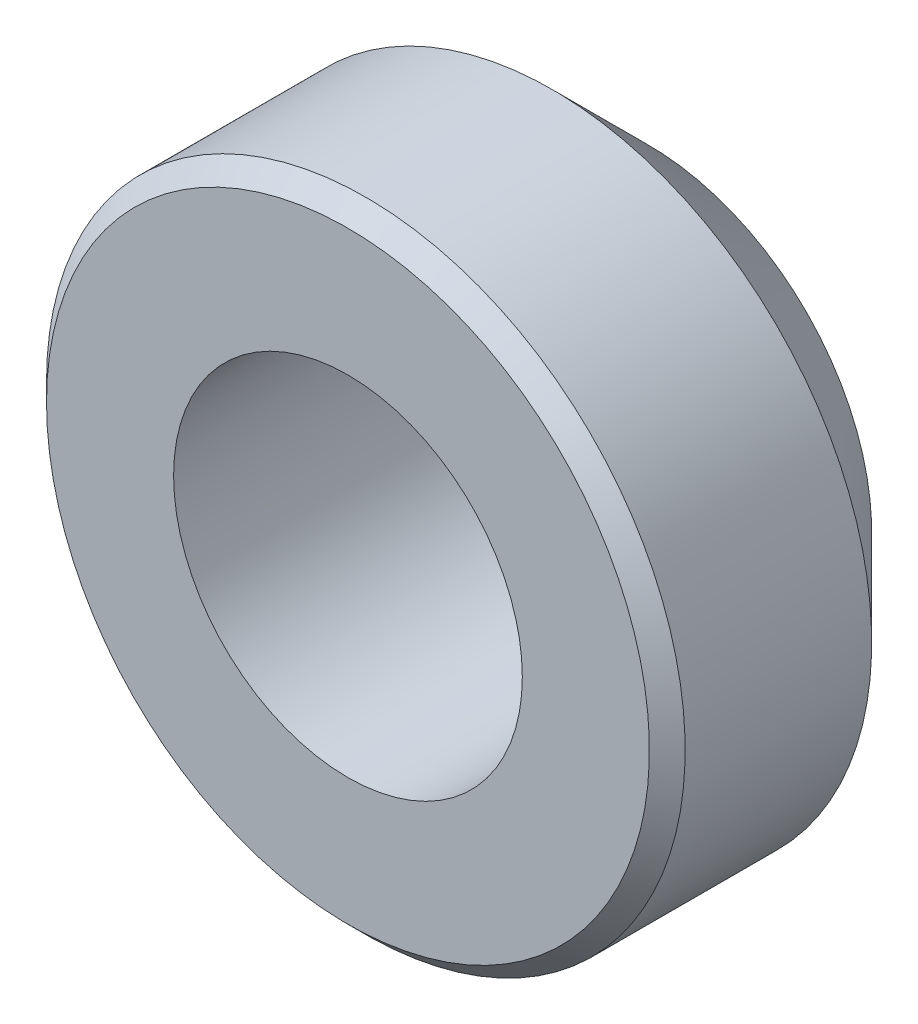
from build123d import *

# Parameters (mm, degrees)
SKETCH2_R          = 1.73355
CUT_EXTRUDE1_DEPTH = 3.9845
CHAMFER1_SIZE      = 0.1778


with BuildPart() as part:
    # Sketch1 → Revolve1 (revolve)
    with BuildSketch(Plane(origin=(0, 0, 0), x_dir=(1, 0, 0), z_dir=(0, 1, 0))):
        Polygon((0, 0), (3.175, 0), (3.175, 2.032), (2.2225, 2.9845), (0, 2.9845), align=None)
    revolve(axis=Axis((0, 0, 0), (0, 0, 1)))

    # Sketch2 → Cut-Extrude1 (cut, through all)
    with BuildSketch(Plane(origin=(0, 0, -2.9845), x_dir=(-1, 0, 0), z_dir=(0, 0, -1))):
        Circle(SKETCH2_R)
    extrude(amount=-CUT_EXTRUDE1_DEPTH, mode=Mode.SUBTRACT)

    # Chamfer1
    chamfer1_edges = [part.edges().sort_by_distance(p)[0] for p in [
        (-3.175, 0, 0),
    ]]
    chamfer(chamfer1_edges, length=CHAMFER1_SIZE)


solid = part.part
